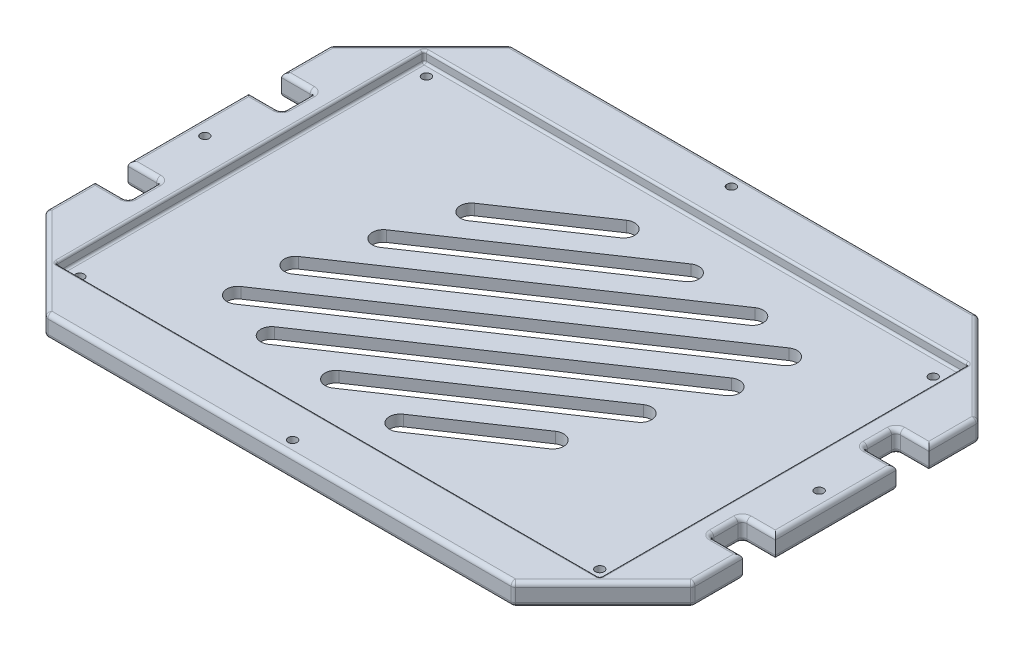
from build123d import *

# Parameters (mm, degrees)
BOSS_EXTRUDE1_DEPTH     = 5
SKETCH4_W               = 248
SKETCH4_H               = 168
CUT_EXTRUDE2_DEPTH      = 5
SKETCH5_R               = 2
SKETCH5_W               = 15
SKETCH5_H               = 15
CUT_EXTRUDE3_DEPTH      = 182.912753813
CUT_EXTRUDE4_DEPTH      = 182.912753813
CUT_EXTRUDE4_DEPTH_BACK = 182.912753813
SKETCH4_3_R             = 2
FILLET1_R               = 2
FILLET2_R               = 1
CUT_EXTRUDE6_DEPTH      = 182.706494105
CUT_EXTRUDE6_DEPTH_BACK = 182.706494105


with BuildPart() as part:
    # Sketch1 → Boss-Extrude1 (new, symmetric)
    with BuildSketch(Plane(origin=(0, 0, 0), x_dir=(1, 0, 0), z_dir=(0, 1, 0))):
        Polygon((-147.5, 64.895923599), (-147.5, -64.895923599), (-106.395923599, -106), (106.395923599, -106), (147.5, -64.895923599), (147.5, 64.895923599), (106.395923599, 106), (-106.395923599, 106), align=None)
    extrude(amount=BOSS_EXTRUDE1_DEPTH, both=True)

    # Sketch4 → Cut-Extrude2 (cut)
    with BuildSketch(Plane(origin=(0, 5, 0), x_dir=(1, 0, 0), z_dir=(0, 1, 0))):
        Rectangle(SKETCH4_W, SKETCH4_H)
    extrude(amount=-CUT_EXTRUDE2_DEPTH, mode=Mode.SUBTRACT)

    # Sketch5 → Cut-Extrude3 (cut, symmetric)
    with BuildSketch(Plane(origin=(0, 5, 0), x_dir=(1, 0, 0), z_dir=(0, 1, 0))):
        with Locations((-140, 0)):
            Circle(SKETCH5_R)
        with Locations((0, 100)):
            Circle(SKETCH5_R)
        with Locations((0, -100)):
            Circle(SKETCH5_R)
        with Locations((-140, 35)):
            Rectangle(SKETCH5_W, SKETCH5_H)
        with Locations((-140, -35)):
            Rectangle(SKETCH5_W, SKETCH5_H)
    cut_extrude3 = extrude(amount=CUT_EXTRUDE3_DEPTH, both=True, mode=Mode.SUBTRACT)

    # Mirror1: Cut-Extrude3 across plane
    add(cut_extrude3.mirror(Plane(origin=(0, 0, 0), x_dir=(0, 0, 1), z_dir=(1, 0, 0))), mode=Mode.SUBTRACT)

    # Sketch4_3 → Cut-Extrude4 (cut, two sides: drawn at the far end of the back side and taken through both)
    with BuildSketch(Plane(origin=(0, 5, 0), x_dir=(1, 0, 0), z_dir=(0, 1, 0)).offset(-CUT_EXTRUDE4_DEPTH_BACK)):
        with Locations((-118, 79)):
            Circle(SKETCH4_3_R)
        with Locations((-118, -79)):
            Circle(SKETCH4_3_R)
        with Locations((116, 76)):
            Circle(SKETCH4_3_R)
        with Locations((116, -76)):
            Circle(SKETCH4_3_R)
    extrude(amount=CUT_EXTRUDE4_DEPTH + CUT_EXTRUDE4_DEPTH_BACK, mode=Mode.SUBTRACT)

    # Fillet1
    fillet1_edges = [part.edges().sort_by_distance(p)[0] for p in [
        (140, 5, 42.5),
        (140, 5, 27.5),
        (140, -5, 27.5),
        (140, -5, 42.5),
        (140, 5, -27.5),
        (140, 5, -42.5),
        (140, -5, -42.5),
        (140, -5, -27.5),
        (-140, -5, 42.5),
        (-140, 5, 42.5),
        (-140, -5, 27.5),
        (-140, 5, 27.5),
        (-140, -5, -27.5),
        (-140, 5, -27.5),
        (-140, -5, -42.5),
        (-140, 5, -42.5),
        (132.5, 5, 35),
        (132.5, 0, 27.5),
        (132.5, -5, 35),
        (132.5, 0, 42.5),
        (132.5, 5, -35),
        (132.5, 0, -42.5),
        (132.5, -5, -35),
        (132.5, 0, -27.5),
        (-132.5, 0, 42.5),
        (-132.5, -5, 35),
        (-132.5, 0, 27.5),
        (-132.5, 5, 35),
        (-132.5, 0, -27.5),
        (-132.5, -5, -35),
        (-132.5, 0, -42.5),
        (-132.5, 5, -35),
        (-126.9479618, -5, 85.4479618),
        (0, -5, 106),
        (126.9479618, -5, 85.4479618),
        (147.5, -5, -53.6979618),
        (147.5, -5, 0),
        (147.5, -5, 53.6979618),
        (126.9479618, -5, -85.4479618),
        (0, -5, -106),
        (-126.9479618, -5, -85.4479618),
        (-147.5, -5, -53.6979618),
        (-147.5, -5, 0),
        (-147.5, -5, 53.6979618),
        (-126.9479618, 5, 85.4479618),
        (0, 5, 106),
        (126.9479618, 5, 85.4479618),
        (147.5, 5, -53.6979618),
        (147.5, 5, 0),
        (147.5, 5, 53.6979618),
        (126.9479618, 5, -85.4479618),
        (0, 5, -106),
        (-126.9479618, 5, -85.4479618),
        (-147.5, 5, -53.6979618),
        (-147.5, 5, 0),
        (-147.5, 5, 53.6979618),
        (-147.5, 0, 64.895923599),
        (-147.5, 0, -64.895923599),
        (-106.395923599, 0, -106),
        (106.395923599, 0, -106),
        (147.5, 0, -64.895923599),
        (-106.395923599, 0, 106),
        (147.5, 0, 64.895923599),
        (106.395923599, 0, 106),
    ]]
    fillet(fillet1_edges, radius=FILLET1_R)

    # Fillet2
    fillet2_edges = [part.edges().sort_by_distance(p)[0] for p in [
        (0, 0, 84),
        (124, 0, 0),
        (0, 0, -84),
        (-124, 0, 0),
        (-124, 2.5, 84),
        (124, 2.5, 84),
        (0, 5, 84),
        (124, 2.5, -84),
        (-124, 2.5, -84),
        (124, 5, 0),
        (0, 5, -84),
        (-124, 5, 0),
    ]]
    fillet(fillet2_edges, radius=FILLET2_R)

    # Sketch7 → Cut-Extrude6 (cut, two sides: drawn at the far end of the back side and taken through both)
    with BuildSketch(Plane(origin=(0, 0, 0), x_dir=(1, 0, 0), z_dir=(0, 1, 0)).offset(-CUT_EXTRUDE6_DEPTH_BACK)):
        with BuildLine():
            Line((-77.400196961, -46.197505456), (71.806625914, 54.486773394))
            ThreePointArc((71.806625914, 54.486773394), (78.748045406, 53.138924949), (77.400196961, 46.197505456))
            Line((77.400196961, 46.197505456), (-71.806625914, -54.486773394))
            ThreePointArc((-71.806625914, -54.486773394), (-78.748045406, -53.138924949), (-77.400196961, -46.197505456))
        make_face()
        with BuildLine():
            Line((-76.153437149, -21.228613011), (48.185581913, 62.674952698))
            ThreePointArc((48.185581913, 62.674952698), (55.127001405, 61.327104253), (53.77915296, 54.385684761))
            Line((53.77915296, 54.385684761), (-70.559866102, -29.517880948))
            ThreePointArc((-70.559866102, -29.517880948), (-77.501285594, -28.170032503), (-76.153437149, -21.228613011))
        make_face()
        with BuildLine():
            Line((-66.6174094, 9.333850482), (16.275269975, 65.269560955))
            ThreePointArc((16.275269975, 65.269560955), (23.216689467, 63.92171251), (21.868841022, 56.980293017))
            Line((21.868841022, 56.980293017), (-61.023838353, 1.044582545))
            ThreePointArc((-61.023838353, 1.044582545), (-67.965257845, 2.39243099), (-66.6174094, 9.333850482))
        make_face()
        with BuildLine():
            Line((-57.081381651, 39.896313976), (-15.635041963, 67.864169212))
            ThreePointArc((-15.635041963, 67.864169212), (-8.693622471, 66.516320767), (-10.041470916, 59.574901274))
            Line((-10.041470916, 59.574901274), (-51.487810604, 31.607046038))
            ThreePointArc((-51.487810604, 31.607046038), (-58.429230096, 32.954894483), (-57.081381651, 39.896313976))
        make_face()
        with BuildLine():
            Line((-48.185581913, -62.674952698), (76.153437149, 21.228613011))
            ThreePointArc((76.153437149, 21.228613011), (77.501285594, 28.170032503), (70.559866102, 29.517880948))
            Line((70.559866102, 29.517880948), (-53.77915296, -54.385684761))
            ThreePointArc((-53.77915296, -54.385684761), (-55.127001405, -61.327104253), (-48.185581913, -62.674952698))
        make_face()
        with BuildLine():
            Line((-16.275269975, -65.269560955), (66.6174094, -9.333850482))
            ThreePointArc((66.6174094, -9.333850482), (67.965257845, -2.39243099), (61.023838353, -1.044582545))
            Line((61.023838353, -1.044582545), (-21.868841022, -56.980293017))
            ThreePointArc((-21.868841022, -56.980293017), (-23.216689467, -63.92171251), (-16.275269975, -65.269560955))
        make_face()
        with BuildLine():
            Line((15.635041963, -67.864169212), (57.081381651, -39.896313976))
            ThreePointArc((57.081381651, -39.896313976), (58.429230096, -32.954894483), (51.487810604, -31.607046038))
            Line((51.487810604, -31.607046038), (10.041470916, -59.574901274))
            ThreePointArc((10.041470916, -59.574901274), (8.693622471, -66.516320767), (15.635041963, -67.864169212))
        make_face()
    extrude(amount=CUT_EXTRUDE6_DEPTH + CUT_EXTRUDE6_DEPTH_BACK, mode=Mode.SUBTRACT)


solid = part.part
